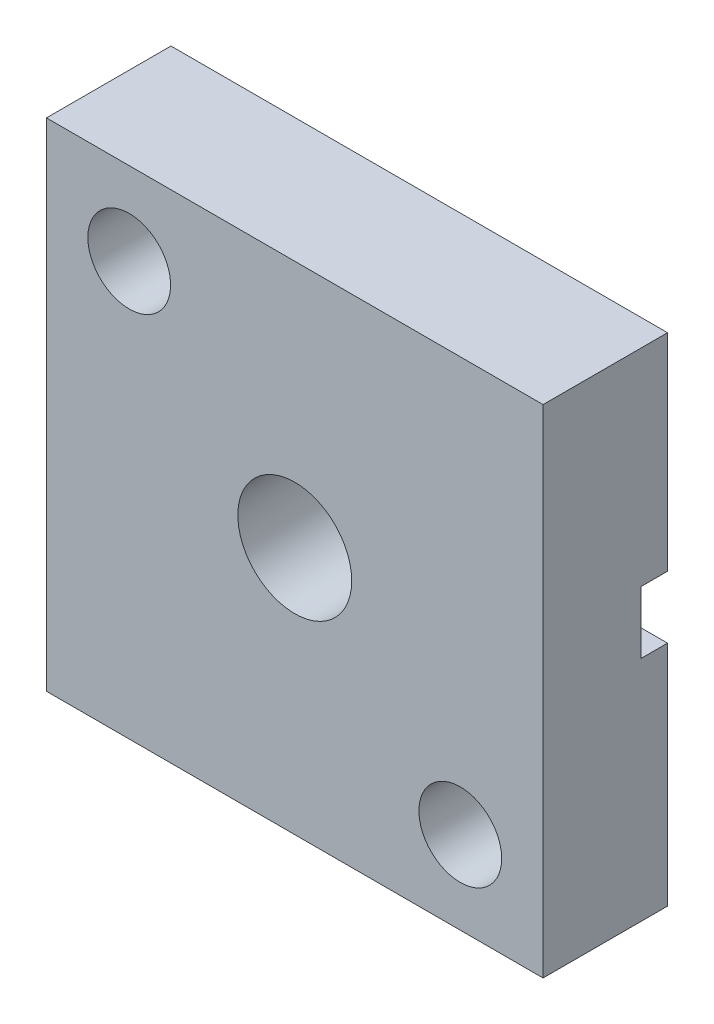
from build123d import *

# Parameters (mm, degrees)
SKETCH1_W      = 19.05
SKETCH1_H      = 19.05
EXTRUDE1_DEPTH = 4.7752
SKETCH2_R      = 2.1844
SKETCH2_R_2    = 1.5875
EXTRUDE2_DEPTH = 5.7752
SKETCH4_W      = 1.016
SKETCH4_H      = 2.3876
EXTRUDE3_DEPTH = 20.05


with BuildPart() as part:
    # Sketch1 → Extrude1 (new body)
    with BuildSketch(Plane.XY):
        with Locations((-131.857958108, -85.722466515)):
            Rectangle(SKETCH1_W, SKETCH1_H)
    extrude(amount=EXTRUDE1_DEPTH)

    # Sketch2 → Extrude2 (cut, through all)
    with BuildSketch(Plane.XY.offset(4.7752)):
        with Locations((-131.857958108, -85.722466515)):
            Circle(SKETCH2_R)
        with Locations((-125.507958108, -92.072466515)):
            Circle(SKETCH2_R_2)
        with Locations(Location((-138.207958108, -79.372466515, 0), (0, 0, 180))):  # turned: the seam where the file's is
            Circle(SKETCH2_R_2)
    extrude(amount=-EXTRUDE2_DEPTH, mode=Mode.SUBTRACT)

    # Sketch4 → Extrude3 (cut, through all)
    with BuildSketch(Plane.ZY.offset(141.382958108)):
        with Locations((0.508, -85.316066515)):
            Rectangle(SKETCH4_W, SKETCH4_H)
    extrude(amount=-EXTRUDE3_DEPTH, mode=Mode.SUBTRACT)


solid = part.part
